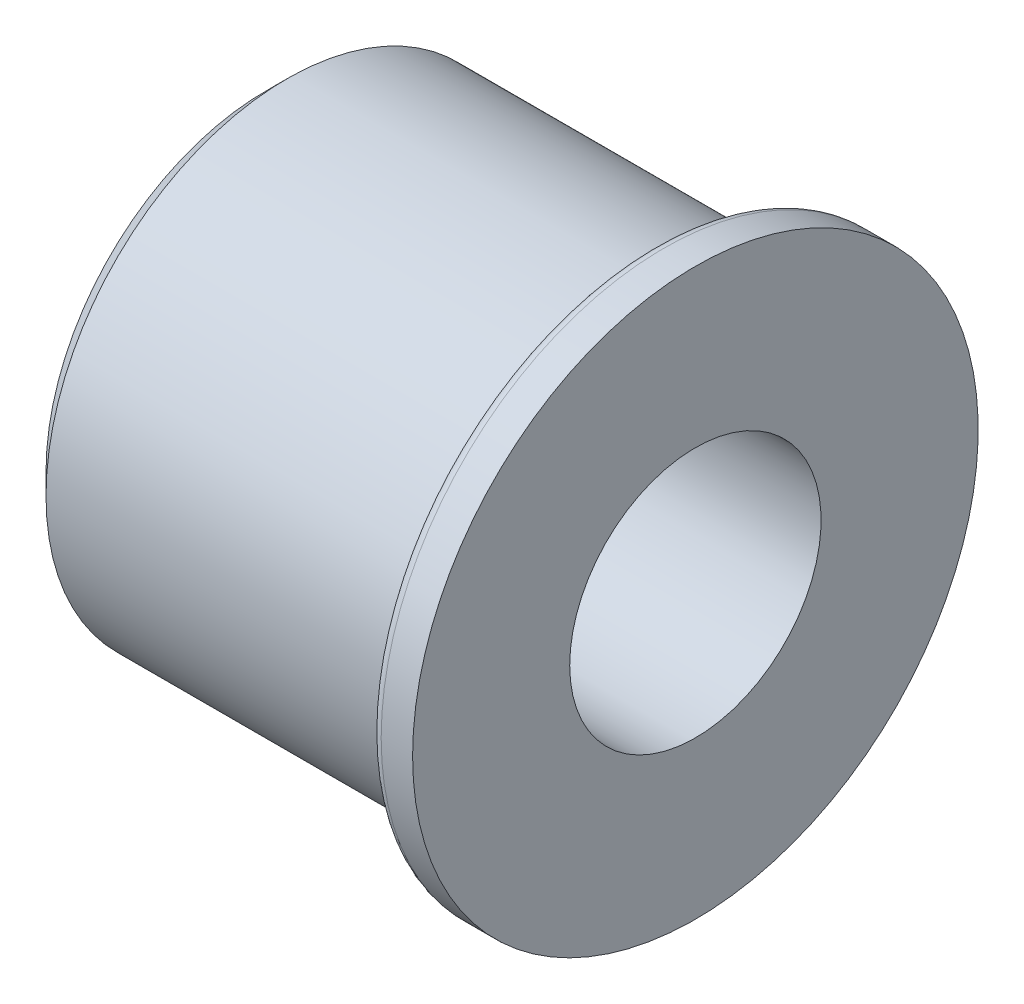
from build123d import *


with BuildPart() as part:
    # Esquisse1 → Révolution1 (revolve)
    with BuildSketch(Plane.XY, mode=Mode.PRIVATE) as r_volution1_sk:
        with BuildLine():
            Line((0, 6), (20.5, 6))
            Line((20.5, 6), (20.5, 13.5))
            Line((20.5, 13.5), (19, 13.5))
            ThreePointArc((19, 13.5), (18.646446609, 13.353553391), (18.5, 13))
            Line((18.5, 13), (18.5, 11.5))
            Line((18.5, 11.5), (1, 11.5))
            Line((1, 11.5), (0, 10.5))
            Line((0, 10.5), (0, 6))
        make_face()
    revolve(r_volution1_sk.sketch.rotate(Axis((0, 0, 0), (1, 0, 0)), 90), axis=Axis((0, 0, 0), (1, 0, 0)))  # turned: the seam where the file's is


solid = part.part
